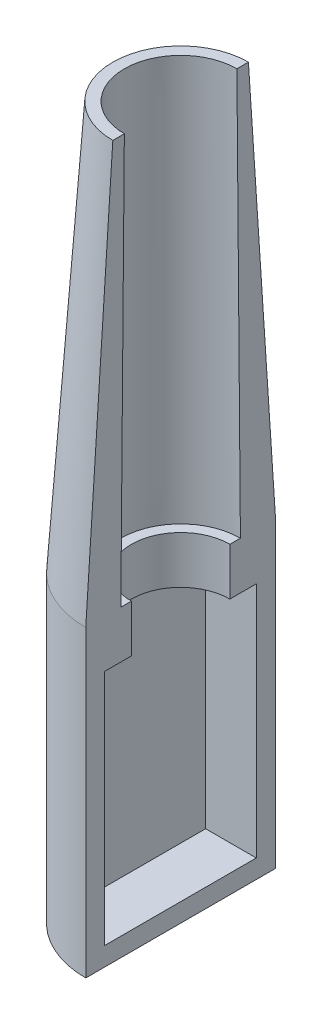
from build123d import *

# Parameters (mm, degrees)
SKETCH2_R                = 25.4
BOSS_EXTRUDE1_DEPTH      = 63.5
BOSS_EXTRUDE1_DEPTH_BACK = 17.78
SKETCH3_R                = 25.4
BOSS_EXTRUDE2_DEPTH      = 109.317536
BOSS_EXTRUDE2_TAPER      = 3.79256
SKETCH4_R                = 15.06855
CUT_EXTRUDE1_DEPTH       = 109.317536
CUT_EXTRUDE1_DRAFT       = 0.49256
SPLIT6_SURFACE_1_BACK    = 204.688
SPLIT6_SURFACE_1_DEPTH   = 409.376
CUT_EXTRUDE3_DEPTH       = 13.559536
SKETCH8_R                = 13.182228497
CUT_EXTRUDE4_DEPTH       = 13.559536


with BuildPart() as part:
    # Sketch2 → Boss-Extrude1 (new, two sides)
    with BuildSketch(Plane(origin=(0, 0, 0), x_dir=(1, 0, 0), z_dir=(0, 1, 0))) as boss_extrude1_sk:
        with Locations(Location((0, 0, 0), (0, 0, 270))):
            Circle(SKETCH2_R)
    extrude(amount=BOSS_EXTRUDE1_DEPTH)
    extrude(boss_extrude1_sk.sketch, amount=-BOSS_EXTRUDE1_DEPTH_BACK)

    # Sketch3 → Boss-Extrude2 (add)
    with BuildSketch(Plane(origin=(0, 63.5, 0), x_dir=(1, 0, 0), z_dir=(0, 1, 0))):
        with Locations(Location((0, 0, 0), (0, 0, 270))):
            Circle(SKETCH3_R)
    extrude(amount=BOSS_EXTRUDE2_DEPTH, taper=BOSS_EXTRUDE2_TAPER)


with BuildPart() as cut_extrude1_tool:
    # Sketch4 → Cut-Extrude1 (with draft: the straight prism first)
    with BuildSketch(Plane(origin=(0, 172.817536, 0), x_dir=(1, 0, 0), z_dir=(0, 1, 0))):
        Circle(SKETCH4_R)
    extrude(amount=-CUT_EXTRUDE1_DEPTH)
    # Cut-Extrude1: the draft: its side faces are tilted about the plane it starts from
    cut_extrude1_sides = [cut_extrude1_tool.faces().sort_by_distance(p)[0] for p in [
        (-15.06855, 118.158768, 0),
    ]]
    draft(cut_extrude1_sides, Plane(origin=(0, 172.817536, 0), x_dir=(1, 0, 0), z_dir=(0, 1, 0)), CUT_EXTRUDE1_DRAFT)


with BuildPart() as part_1:
    add(part.part)

    # Cut-Extrude1: cut by cut_extrude1_tool
    add(cut_extrude1_tool.part, mode=Mode.SUBTRACT)

    # Split6: cut with a surface, the side behind it stays
    # Split6 surface: a surface, the sketch's curves swept straight by 409.376 mm
    with BuildLine(Plane(origin=(0, 0, 0), x_dir=(1, 0, 0), z_dir=(0, 1, 0)).offset(-SPLIT6_SURFACE_1_BACK), mode=Mode.PRIVATE) as split6_surface_1_path:
        Line((0, 25.4), (0, -25.4))
    split6_surface_1 = Shell.extrude(split6_surface_1_path.wire(), (0 * SPLIT6_SURFACE_1_DEPTH, 1 * SPLIT6_SURFACE_1_DEPTH, 0 * SPLIT6_SURFACE_1_DEPTH))
    split(bisect_by=split6_surface_1, keep=Keep.BOTTOM)

    # Sketch7 → Cut-Extrude3 (cut)
    with BuildSketch(Plane(origin=(0, 0, 0), x_dir=(0, 0, -1), z_dir=(1, 0, 0))):
        Polygon((-20.392899445, 0), (-20.392899445, 50.791761633), (20.25247775, 50.791761633), (20.25247775, -12.77676991), (-20.392899445, -12.77676991), align=None)
    extrude(amount=-CUT_EXTRUDE3_DEPTH, mode=Mode.SUBTRACT)

    # Sketch8 → Cut-Extrude4 (cut)
    with BuildSketch(Plane(origin=(0, 63.5, 0), x_dir=(1, 0, 0), z_dir=(0, 1, 0))):
        Circle(SKETCH8_R)
    extrude(amount=-CUT_EXTRUDE4_DEPTH, mode=Mode.SUBTRACT)


solid = part_1.part
